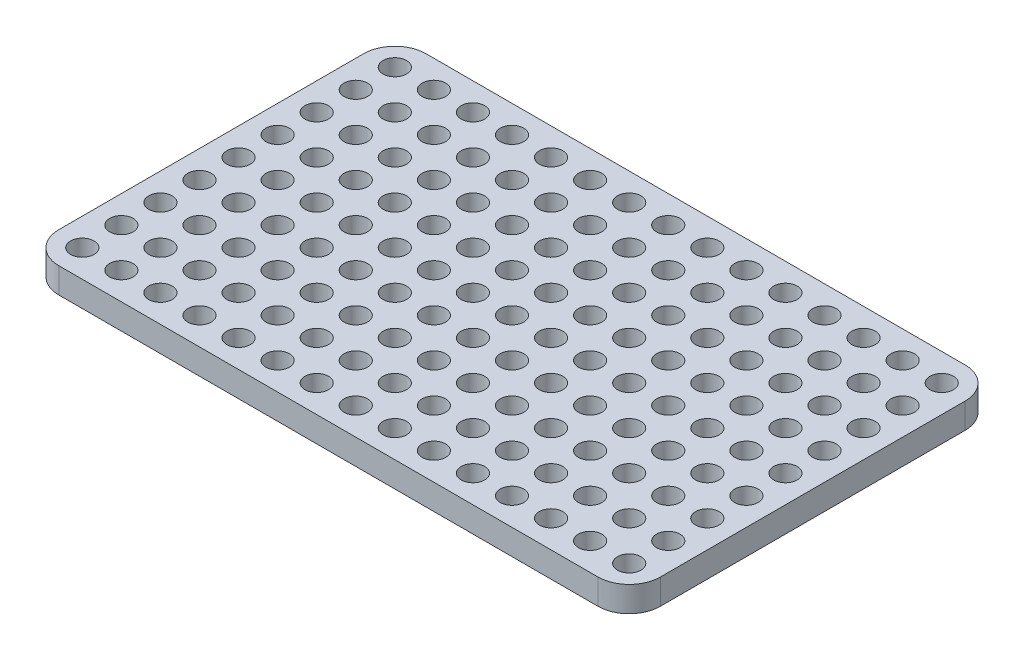
from build123d import *

# Parameters (mm, degrees)
SKETCH1_R           = 1.5025
BOSS_EXTRUDE1_DEPTH = 3.25


with BuildPart() as part:
    # Sketch1 → Boss-Extrude1 (new body)
    with BuildSketch(Plane(origin=(0, 0, 0), x_dir=(1, 0, 0), z_dir=(0, 1, 0))):
        with BuildLine():
            Line((-34.5, 23.5), (34.5, 23.5))
            ThreePointArc((34.5, 23.5), (37.328427125, 22.328427125), (38.5, 19.5))
            Line((38.5, 19.5), (38.5, -19.5))
            ThreePointArc((38.5, -19.5), (37.328427125, -22.328427125), (34.5, -23.5))
            Line((34.5, -23.5), (-34.5, -23.5))
            ThreePointArc((-34.5, -23.5), (-37.328427125, -22.328427125), (-38.5, -19.5))
            Line((-38.5, -19.5), (-38.5, 19.5))
            ThreePointArc((-38.5, 19.5), (-37.328427125, 22.328427125), (-34.5, 23.5))
        make_face()
        with Locations((-35, -20)):
            Circle(SKETCH1_R, mode=Mode.SUBTRACT)
        with Locations((-30, -20)):
            Circle(SKETCH1_R, mode=Mode.SUBTRACT)
        with Locations((-25, -20)):
            Circle(SKETCH1_R, mode=Mode.SUBTRACT)
        with Locations((-20, -20)):
            Circle(SKETCH1_R, mode=Mode.SUBTRACT)
        with Locations((-15, -20)):
            Circle(SKETCH1_R, mode=Mode.SUBTRACT)
        with Locations((-10, -20)):
            Circle(SKETCH1_R, mode=Mode.SUBTRACT)
        with Locations((-5, -20)):
            Circle(SKETCH1_R, mode=Mode.SUBTRACT)
        with Locations((0, -20)):
            Circle(SKETCH1_R, mode=Mode.SUBTRACT)
        with Locations((5, -20)):
            Circle(SKETCH1_R, mode=Mode.SUBTRACT)
        with Locations((10, -20)):
            Circle(SKETCH1_R, mode=Mode.SUBTRACT)
        with Locations((15, -20)):
            Circle(SKETCH1_R, mode=Mode.SUBTRACT)
        with Locations((20, -20)):
            Circle(SKETCH1_R, mode=Mode.SUBTRACT)
        with Locations((25, -20)):
            Circle(SKETCH1_R, mode=Mode.SUBTRACT)
        with Locations((30, -20)):
            Circle(SKETCH1_R, mode=Mode.SUBTRACT)
        with Locations((35, -20)):
            Circle(SKETCH1_R, mode=Mode.SUBTRACT)
        with Locations((-35, -15)):
            Circle(SKETCH1_R, mode=Mode.SUBTRACT)
        with Locations((-30, -15)):
            Circle(SKETCH1_R, mode=Mode.SUBTRACT)
        with Locations((-25, -15)):
            Circle(SKETCH1_R, mode=Mode.SUBTRACT)
        with Locations((-20, -15)):
            Circle(SKETCH1_R, mode=Mode.SUBTRACT)
        with Locations((-15, -15)):
            Circle(SKETCH1_R, mode=Mode.SUBTRACT)
        with Locations((-10, -15)):
            Circle(SKETCH1_R, mode=Mode.SUBTRACT)
        with Locations((-5, -15)):
            Circle(SKETCH1_R, mode=Mode.SUBTRACT)
        with Locations((0, -15)):
            Circle(SKETCH1_R, mode=Mode.SUBTRACT)
        with Locations((5, -15)):
            Circle(SKETCH1_R, mode=Mode.SUBTRACT)
        with Locations((10, -15)):
            Circle(SKETCH1_R, mode=Mode.SUBTRACT)
        with Locations((15, -15)):
            Circle(SKETCH1_R, mode=Mode.SUBTRACT)
        with Locations((20, -15)):
            Circle(SKETCH1_R, mode=Mode.SUBTRACT)
        with Locations((25, -15)):
            Circle(SKETCH1_R, mode=Mode.SUBTRACT)
        with Locations((30, -15)):
            Circle(SKETCH1_R, mode=Mode.SUBTRACT)
        with Locations((35, -15)):
            Circle(SKETCH1_R, mode=Mode.SUBTRACT)
        with Locations((-35, -10)):
            Circle(SKETCH1_R, mode=Mode.SUBTRACT)
        with Locations((-30, -10)):
            Circle(SKETCH1_R, mode=Mode.SUBTRACT)
        with Locations((-25, -10)):
            Circle(SKETCH1_R, mode=Mode.SUBTRACT)
        with Locations((-20, -10)):
            Circle(SKETCH1_R, mode=Mode.SUBTRACT)
        with Locations((-15, -10)):
            Circle(SKETCH1_R, mode=Mode.SUBTRACT)
        with Locations((-10, -10)):
            Circle(SKETCH1_R, mode=Mode.SUBTRACT)
        with Locations((-5, -10)):
            Circle(SKETCH1_R, mode=Mode.SUBTRACT)
        with Locations((0, -10)):
            Circle(SKETCH1_R, mode=Mode.SUBTRACT)
        with Locations((5, -10)):
            Circle(SKETCH1_R, mode=Mode.SUBTRACT)
        with Locations((10, -10)):
            Circle(SKETCH1_R, mode=Mode.SUBTRACT)
        with Locations((15, -10)):
            Circle(SKETCH1_R, mode=Mode.SUBTRACT)
        with Locations((20, -10)):
            Circle(SKETCH1_R, mode=Mode.SUBTRACT)
        with Locations((25, -10)):
            Circle(SKETCH1_R, mode=Mode.SUBTRACT)
        with Locations((30, -10)):
            Circle(SKETCH1_R, mode=Mode.SUBTRACT)
        with Locations((35, -10)):
            Circle(SKETCH1_R, mode=Mode.SUBTRACT)
        with Locations((-35, -5)):
            Circle(SKETCH1_R, mode=Mode.SUBTRACT)
        with Locations((-30, -5)):
            Circle(SKETCH1_R, mode=Mode.SUBTRACT)
        with Locations((-25, -5)):
            Circle(SKETCH1_R, mode=Mode.SUBTRACT)
        with Locations((-20, -5)):
            Circle(SKETCH1_R, mode=Mode.SUBTRACT)
        with Locations((-15, -5)):
            Circle(SKETCH1_R, mode=Mode.SUBTRACT)
        with Locations((-10, -5)):
            Circle(SKETCH1_R, mode=Mode.SUBTRACT)
        with Locations((-5, -5)):
            Circle(SKETCH1_R, mode=Mode.SUBTRACT)
        with Locations((0, -5)):
            Circle(SKETCH1_R, mode=Mode.SUBTRACT)
        with Locations((5, -5)):
            Circle(SKETCH1_R, mode=Mode.SUBTRACT)
        with Locations((10, -5)):
            Circle(SKETCH1_R, mode=Mode.SUBTRACT)
        with Locations((15, -5)):
            Circle(SKETCH1_R, mode=Mode.SUBTRACT)
        with Locations((20, -5)):
            Circle(SKETCH1_R, mode=Mode.SUBTRACT)
        with Locations((25, -5)):
            Circle(SKETCH1_R, mode=Mode.SUBTRACT)
        with Locations((30, -5)):
            Circle(SKETCH1_R, mode=Mode.SUBTRACT)
        with Locations((35, -5)):
            Circle(SKETCH1_R, mode=Mode.SUBTRACT)
        with Locations((-35, 0)):
            Circle(SKETCH1_R, mode=Mode.SUBTRACT)
        with Locations((-30, 0)):
            Circle(SKETCH1_R, mode=Mode.SUBTRACT)
        with Locations((-25, 0)):
            Circle(SKETCH1_R, mode=Mode.SUBTRACT)
        with Locations((-20, 0)):
            Circle(SKETCH1_R, mode=Mode.SUBTRACT)
        with Locations((-15, 0)):
            Circle(SKETCH1_R, mode=Mode.SUBTRACT)
        with Locations((-10, 0)):
            Circle(SKETCH1_R, mode=Mode.SUBTRACT)
        with Locations((-5, 0)):
            Circle(SKETCH1_R, mode=Mode.SUBTRACT)
        Circle(SKETCH1_R, mode=Mode.SUBTRACT)
        with Locations((5, 0)):
            Circle(SKETCH1_R, mode=Mode.SUBTRACT)
        with Locations((10, 0)):
            Circle(SKETCH1_R, mode=Mode.SUBTRACT)
        with Locations((15, 0)):
            Circle(SKETCH1_R, mode=Mode.SUBTRACT)
        with Locations((20, 0)):
            Circle(SKETCH1_R, mode=Mode.SUBTRACT)
        with Locations((25, 0)):
            Circle(SKETCH1_R, mode=Mode.SUBTRACT)
        with Locations((30, 0)):
            Circle(SKETCH1_R, mode=Mode.SUBTRACT)
        with Locations((35, 0)):
            Circle(SKETCH1_R, mode=Mode.SUBTRACT)
        with Locations((-35, 5)):
            Circle(SKETCH1_R, mode=Mode.SUBTRACT)
        with Locations((-30, 5)):
            Circle(SKETCH1_R, mode=Mode.SUBTRACT)
        with Locations((-25, 5)):
            Circle(SKETCH1_R, mode=Mode.SUBTRACT)
        with Locations((-20, 5)):
            Circle(SKETCH1_R, mode=Mode.SUBTRACT)
        with Locations((-15, 5)):
            Circle(SKETCH1_R, mode=Mode.SUBTRACT)
        with Locations((-10, 5)):
            Circle(SKETCH1_R, mode=Mode.SUBTRACT)
        with Locations((-5, 5)):
            Circle(SKETCH1_R, mode=Mode.SUBTRACT)
        with Locations((0, 5)):
            Circle(SKETCH1_R, mode=Mode.SUBTRACT)
        with Locations((5, 5)):
            Circle(SKETCH1_R, mode=Mode.SUBTRACT)
        with Locations((10, 5)):
            Circle(SKETCH1_R, mode=Mode.SUBTRACT)
        with Locations((15, 5)):
            Circle(SKETCH1_R, mode=Mode.SUBTRACT)
        with Locations((20, 5)):
            Circle(SKETCH1_R, mode=Mode.SUBTRACT)
        with Locations((25, 5)):
            Circle(SKETCH1_R, mode=Mode.SUBTRACT)
        with Locations((30, 5)):
            Circle(SKETCH1_R, mode=Mode.SUBTRACT)
        with Locations((35, 5)):
            Circle(SKETCH1_R, mode=Mode.SUBTRACT)
        with Locations((-35, 10)):
            Circle(SKETCH1_R, mode=Mode.SUBTRACT)
        with Locations((-30, 10)):
            Circle(SKETCH1_R, mode=Mode.SUBTRACT)
        with Locations((-25, 10)):
            Circle(SKETCH1_R, mode=Mode.SUBTRACT)
        with Locations((-20, 10)):
            Circle(SKETCH1_R, mode=Mode.SUBTRACT)
        with Locations((-15, 10)):
            Circle(SKETCH1_R, mode=Mode.SUBTRACT)
        with Locations((-10, 10)):
            Circle(SKETCH1_R, mode=Mode.SUBTRACT)
        with Locations((-5, 10)):
            Circle(SKETCH1_R, mode=Mode.SUBTRACT)
        with Locations((0, 10)):
            Circle(SKETCH1_R, mode=Mode.SUBTRACT)
        with Locations((5, 10)):
            Circle(SKETCH1_R, mode=Mode.SUBTRACT)
        with Locations((10, 10)):
            Circle(SKETCH1_R, mode=Mode.SUBTRACT)
        with Locations((15, 10)):
            Circle(SKETCH1_R, mode=Mode.SUBTRACT)
        with Locations((20, 10)):
            Circle(SKETCH1_R, mode=Mode.SUBTRACT)
        with Locations((25, 10)):
            Circle(SKETCH1_R, mode=Mode.SUBTRACT)
        with Locations((30, 10)):
            Circle(SKETCH1_R, mode=Mode.SUBTRACT)
        with Locations((35, 10)):
            Circle(SKETCH1_R, mode=Mode.SUBTRACT)
        with Locations((-35, 15)):
            Circle(SKETCH1_R, mode=Mode.SUBTRACT)
        with Locations((-30, 15)):
            Circle(SKETCH1_R, mode=Mode.SUBTRACT)
        with Locations((-25, 15)):
            Circle(SKETCH1_R, mode=Mode.SUBTRACT)
        with Locations((-20, 15)):
            Circle(SKETCH1_R, mode=Mode.SUBTRACT)
        with Locations((-15, 15)):
            Circle(SKETCH1_R, mode=Mode.SUBTRACT)
        with Locations((-10, 15)):
            Circle(SKETCH1_R, mode=Mode.SUBTRACT)
        with Locations((-5, 15)):
            Circle(SKETCH1_R, mode=Mode.SUBTRACT)
        with Locations((0, 15)):
            Circle(SKETCH1_R, mode=Mode.SUBTRACT)
        with Locations((5, 15)):
            Circle(SKETCH1_R, mode=Mode.SUBTRACT)
        with Locations((10, 15)):
            Circle(SKETCH1_R, mode=Mode.SUBTRACT)
        with Locations((15, 15)):
            Circle(SKETCH1_R, mode=Mode.SUBTRACT)
        with Locations((20, 15)):
            Circle(SKETCH1_R, mode=Mode.SUBTRACT)
        with Locations((25, 15)):
            Circle(SKETCH1_R, mode=Mode.SUBTRACT)
        with Locations((30, 15)):
            Circle(SKETCH1_R, mode=Mode.SUBTRACT)
        with Locations((35, 15)):
            Circle(SKETCH1_R, mode=Mode.SUBTRACT)
        with Locations((-35, 20)):
            Circle(SKETCH1_R, mode=Mode.SUBTRACT)
        with Locations((-30, 20)):
            Circle(SKETCH1_R, mode=Mode.SUBTRACT)
        with Locations((-25, 20)):
            Circle(SKETCH1_R, mode=Mode.SUBTRACT)
        with Locations((-20, 20)):
            Circle(SKETCH1_R, mode=Mode.SUBTRACT)
        with Locations((-15, 20)):
            Circle(SKETCH1_R, mode=Mode.SUBTRACT)
        with Locations((-10, 20)):
            Circle(SKETCH1_R, mode=Mode.SUBTRACT)
        with Locations((-5, 20)):
            Circle(SKETCH1_R, mode=Mode.SUBTRACT)
        with Locations((0, 20)):
            Circle(SKETCH1_R, mode=Mode.SUBTRACT)
        with Locations((5, 20)):
            Circle(SKETCH1_R, mode=Mode.SUBTRACT)
        with Locations((10, 20)):
            Circle(SKETCH1_R, mode=Mode.SUBTRACT)
        with Locations((15, 20)):
            Circle(SKETCH1_R, mode=Mode.SUBTRACT)
        with Locations((20, 20)):
            Circle(SKETCH1_R, mode=Mode.SUBTRACT)
        with Locations((25, 20)):
            Circle(SKETCH1_R, mode=Mode.SUBTRACT)
        with Locations((30, 20)):
            Circle(SKETCH1_R, mode=Mode.SUBTRACT)
        with Locations((35, 20)):
            Circle(SKETCH1_R, mode=Mode.SUBTRACT)
    extrude(amount=BOSS_EXTRUDE1_DEPTH)


solid = part.part
